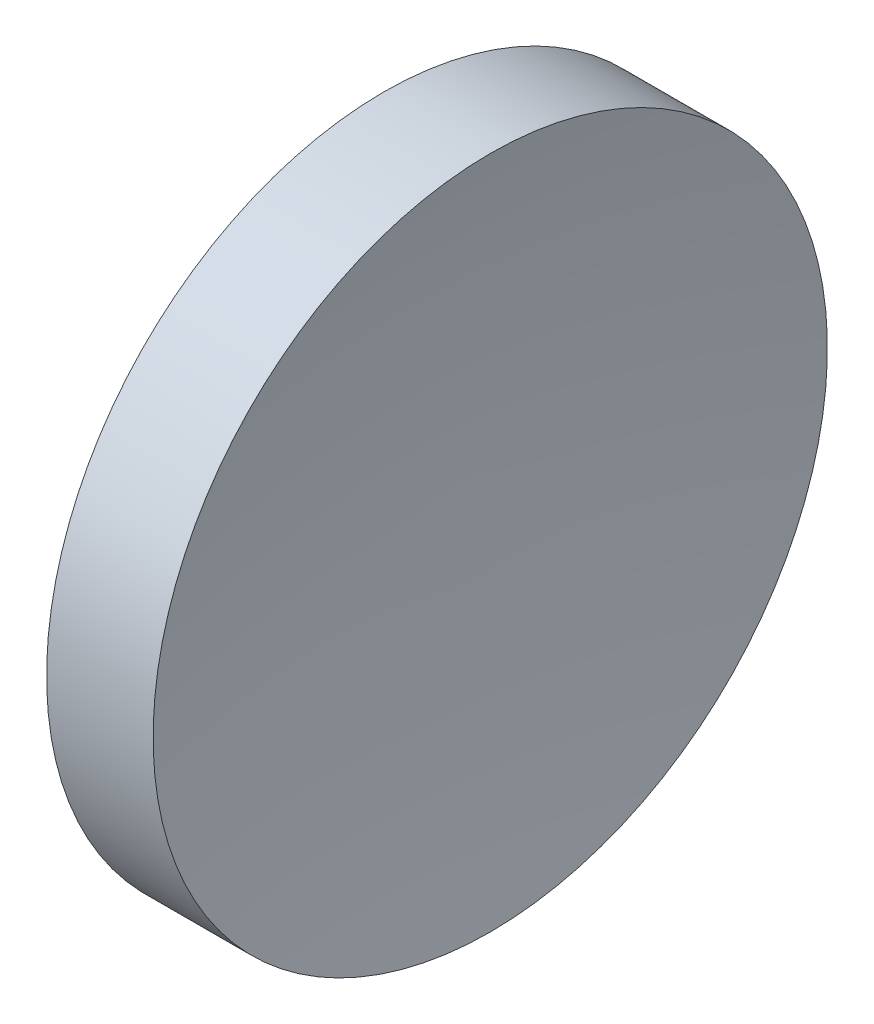
from build123d import *


with BuildPart() as part:
    # 草图1 → 旋转1 (revolve)
    with BuildSketch(Plane.XY, mode=Mode.PRIVATE) as revolve_1_sk:
        with BuildLine():
            Line((97.090443968, 52.178082298), (95.090443968, 52.178082298))
            ThreePointArc((95.090443968, 52.178082298), (94.869409657, 58.550450751), (94.083906719, 64.878082298))
            Line((94.083906719, 64.878082298), (96.090443968, 64.878082298))
            Line((96.090443968, 64.878082298), (98.096981218, 64.878082298))
            ThreePointArc((98.096981218, 64.878082298), (97.31147828, 58.550450751), (97.090443968, 52.178082298))
        make_face()
    revolve(revolve_1_sk.sketch.rotate(Axis((89.858656454, 52.178082298, 0), (1, 0, 0)), 180), axis=Axis((89.858656454, 52.178082298, 0), (1, 0, 0)))  # turned: the seam where the file's is


solid = part.part
